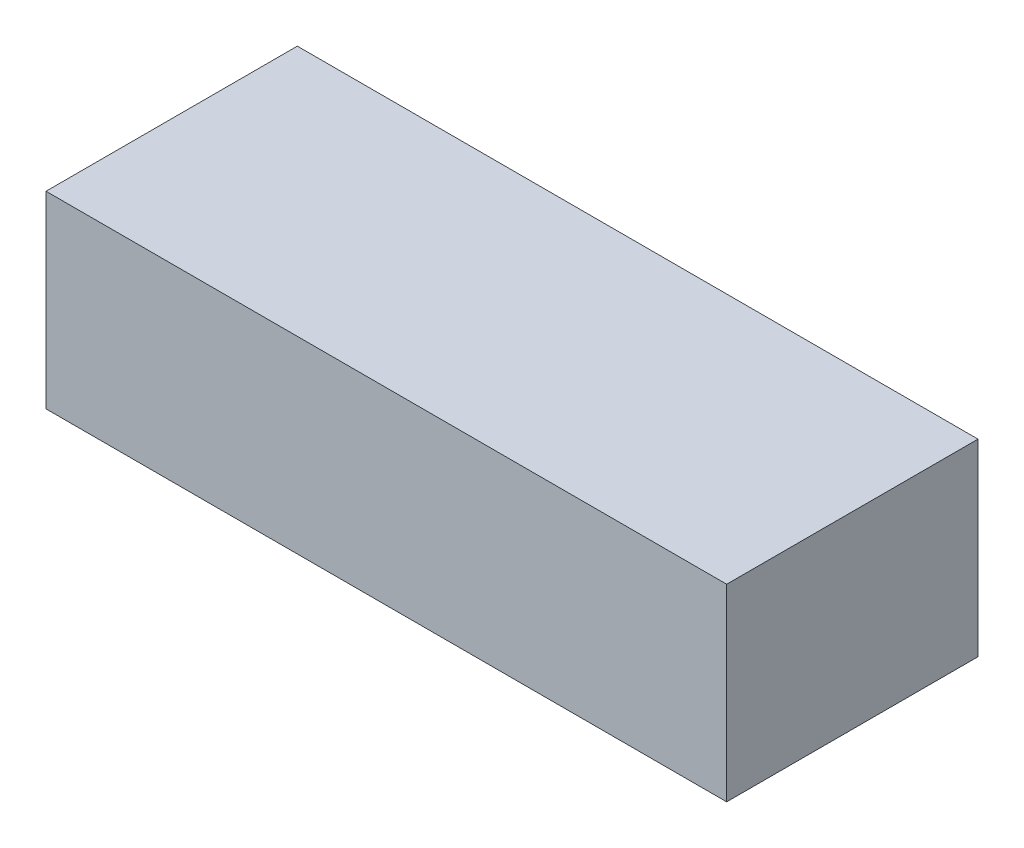
from build123d import *

# Parameters (mm, degrees)
SKETCH2_W           = 24
SKETCH2_H           = 18
BOSS_EXTRUDE1_DEPTH = 65


with BuildPart() as part:
    # Sketch2 → Boss-Extrude1 (new body)
    with BuildSketch(Plane(origin=(0, 0, 0), x_dir=(0, 0, -1), z_dir=(1, 0, 0))):
        Rectangle(SKETCH2_W, SKETCH2_H)
    extrude(amount=BOSS_EXTRUDE1_DEPTH)


solid = part.part
